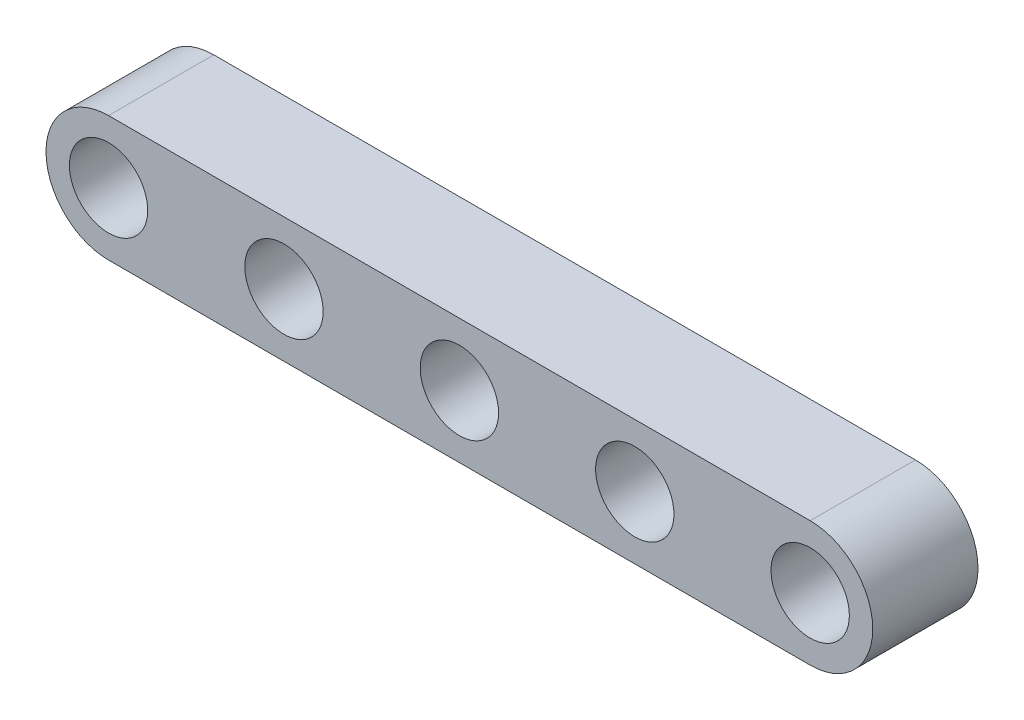
from build123d import *

# Parameters (mm, degrees)
SKETCH1_R           = 1.675
BOSS_EXTRUDE1_DEPTH = 2.25


with BuildPart() as part:
    # Sketch1 → Boss-Extrude1 (new body, symmetric)
    with BuildSketch(Plane.XY):
        with BuildLine():
            Line((-15, 2.675), (15, 2.675))
            ThreePointArc((15, 2.675), (17.675, 0), (15, -2.675))
            Line((15, -2.675), (-15, -2.675))
            ThreePointArc((-15, -2.675), (-17.675, 0), (-15, 2.675))
        make_face()
        with Locations((-15, 0)):
            Circle(SKETCH1_R, mode=Mode.SUBTRACT)
        with Locations((-7.5, 0)):
            Circle(SKETCH1_R, mode=Mode.SUBTRACT)
        Circle(SKETCH1_R, mode=Mode.SUBTRACT)
        with Locations((7.5, 0)):
            Circle(SKETCH1_R, mode=Mode.SUBTRACT)
        with Locations((15, 0)):
            Circle(SKETCH1_R, mode=Mode.SUBTRACT)
    extrude(amount=BOSS_EXTRUDE1_DEPTH, both=True)


solid = part.part
